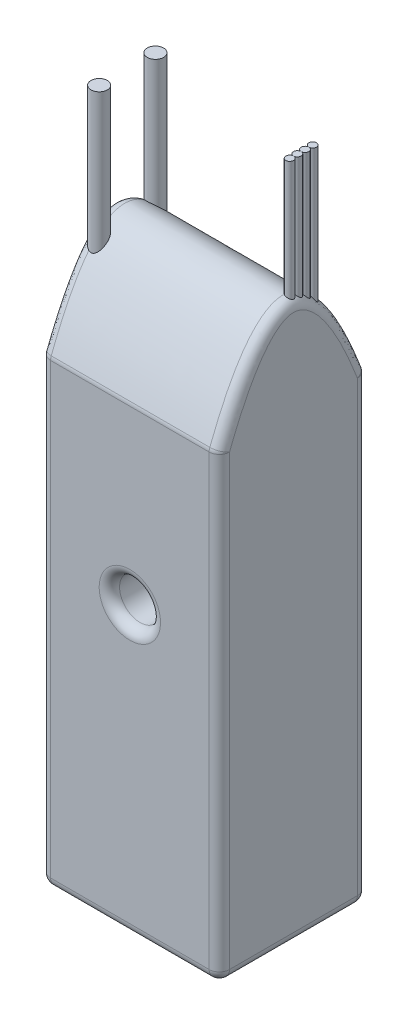
from build123d import *

# Parameters (mm, degrees)
SKETCH2_W             = 35
SKETCH2_H             = 29
BOSS_EXTRUDE1_DEPTH   = 109
CUT_EXTRUDE1_DEPTH    = 35
BOSS_EXTRUDE3_START   = -2
SKETCH4_R             = 1.6
BOSS_EXTRUDE3_DEPTH   = 130
BOSS_EXTRUDE3_2_DEPTH = 130
SKETCH4_R_2           = 0.75
BOSS_EXTRUDE3_3_DEPTH = 130
BOSS_EXTRUDE3_4_DEPTH = 130
BOSS_EXTRUDE3_5_DEPTH = 130
BOSS_EXTRUDE3_6_DEPTH = 130
FILLET1_R             = 2
SKETCH5_R             = 4
CUT_EXTRUDE2_DEPTH    = 29
FILLET2_R             = 2


with BuildPart() as part:
    # Sketch2 → Boss-Extrude1 (new body)
    with BuildSketch(Plane(origin=(0, 0, 0), x_dir=(1, 0, 0), z_dir=(0, 1, 0))):
        Rectangle(SKETCH2_W, SKETCH2_H)
    extrude(amount=BOSS_EXTRUDE1_DEPTH)

    # Sketch3 → Cut-Extrude1 (cut)
    with BuildSketch(Plane(origin=(17.5, 0, 0), x_dir=(0, 0, -1), z_dir=(1, 0, 0))):
        with BuildLine():
            add(Edge.make_bspline(
                [(0, 109), (7.25, 109), (14.5, 90)],
                knots=[0.5, 0.5, 0.5, 1, 1, 1], degree=2))
            Line((14.5, 90), (14.5, 109))
            Line((14.5, 109), (0, 109))
        make_face()
        with BuildLine():
            Line((-14.5, 109), (-14.5, 90))
            add(Edge.make_bspline(
                [(-14.5, 90), (-7.25, 109), (0, 109)],
                knots=[0, 0, 0, 0.5, 0.5, 0.5], degree=2))
            Line((0, 109), (-14.5, 109))
        make_face()
    extrude(amount=-CUT_EXTRUDE1_DEPTH, mode=Mode.SUBTRACT)

    # Fillet1
    fillet1_edges = [part.edges().sort_by_distance(p)[0] for p in [
        (-17.5, 45, -14.5),
        (17.5, 45, -14.5),
        (0, 90, -14.5),
        (17.5, 101.320451781, 9.218474052),
        (-17.5, 101.320451781, 9.218474052),
        (17.5, 45, 14.5),
        (-17.5, 45, 14.5),
        (0, 90, 14.5),
        (0, 0, 14.5),
        (-17.5, 0, 0),
        (0, 0, -14.5),
        (17.5, 0, 0),
    ]]
    fillet(fillet1_edges, radius=FILLET1_R)

    # Sketch5 → Cut-Extrude2 (cut)
    with BuildSketch(Plane.XY.offset(14.5)):
        with Locations((0, 56)):
            Circle(SKETCH5_R)
    extrude(amount=-CUT_EXTRUDE2_DEPTH, mode=Mode.SUBTRACT)

    # Fillet2
    fillet2_edges = [part.edges().sort_by_distance(p)[0] for p in [
        (-4, 56, 14.5),
        (-4, 56, -14.5),
    ]]
    fillet(fillet2_edges, radius=FILLET2_R)


with BuildPart() as body_2:
    # Sketch4 → Boss-Extrude3 (new body)
    with BuildSketch(Plane.XZ.offset(BOSS_EXTRUDE3_START)):
        with Locations((-15, -5.5)):
            Circle(SKETCH4_R)
    extrude(amount=-BOSS_EXTRUDE3_DEPTH)


with BuildPart() as body_3:
    # Sketch4 → Boss-Extrude3 2 (new body)
    with BuildSketch(Plane.XZ.offset(BOSS_EXTRUDE3_START)):
        with Locations((-15, 5.5)):
            Circle(SKETCH4_R)
    extrude(amount=-BOSS_EXTRUDE3_2_DEPTH)


with BuildPart() as body_4:
    # Sketch4 → Boss-Extrude3 3 (new body)
    with BuildSketch(Plane.XZ.offset(BOSS_EXTRUDE3_START)):
        with Locations((16, -5.25)):
            Circle(SKETCH4_R_2)
    extrude(amount=-BOSS_EXTRUDE3_3_DEPTH)


with BuildPart() as body_5:
    # Sketch4 → Boss-Extrude3 4 (new body)
    with BuildSketch(Plane.XZ.offset(BOSS_EXTRUDE3_START)):
        with Locations((16, -3.75)):
            Circle(SKETCH4_R_2)
    extrude(amount=-BOSS_EXTRUDE3_4_DEPTH)


with BuildPart() as body_6:
    # Sketch4 → Boss-Extrude3 5 (new body)
    with BuildSketch(Plane.XZ.offset(BOSS_EXTRUDE3_START)):
        with Locations((16, -2.25)):
            Circle(SKETCH4_R_2)
    extrude(amount=-BOSS_EXTRUDE3_5_DEPTH)


with BuildPart() as body_7:
    # Sketch4 → Boss-Extrude3 6 (new body)
    with BuildSketch(Plane.XZ.offset(BOSS_EXTRUDE3_START)):
        with Locations((16, -0.75)):
            Circle(SKETCH4_R_2)
    extrude(amount=-BOSS_EXTRUDE3_6_DEPTH)


solid = Compound([part.part, body_2.part, body_3.part, body_4.part, body_5.part, body_6.part, body_7.part])
